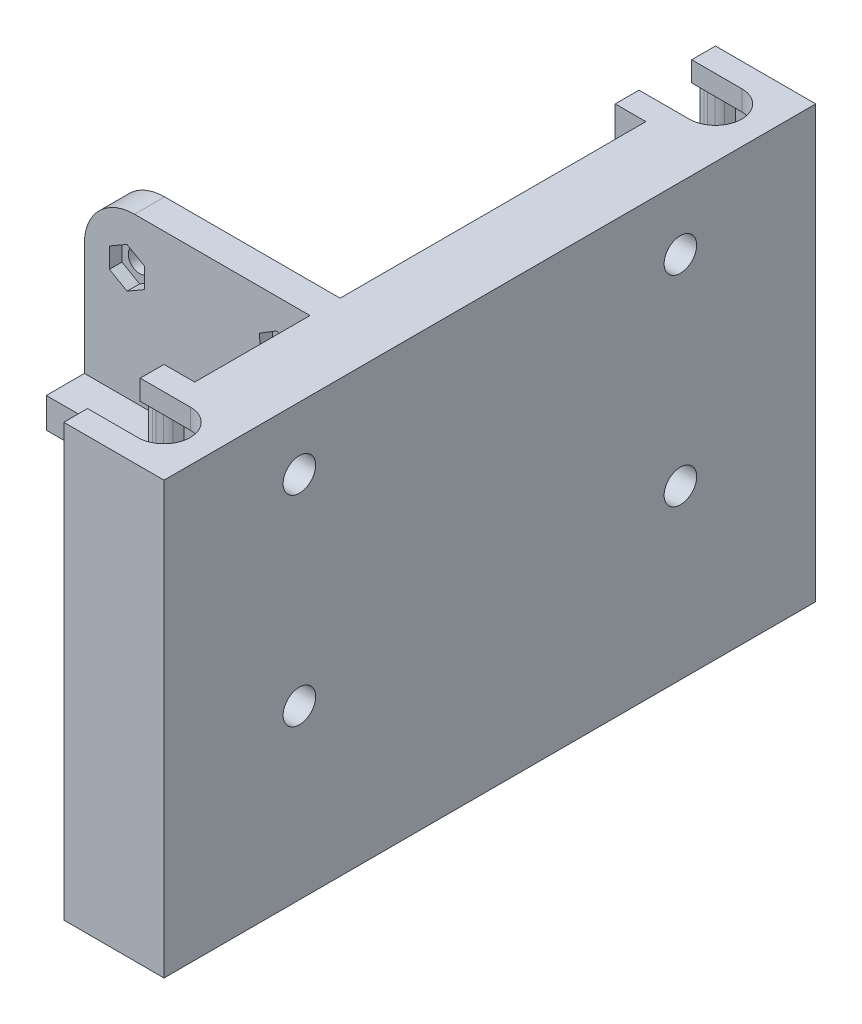
from build123d import *

# Parameters (mm, degrees)
BOSS_EXTRUDE1_DEPTH = 86
CUT_EXTRUDE1_REACH  = 88
CUT_EXTRUDE2_START  = -4
CUT_EXTRUDE2_DEPTH  = 17.2
CUT_EXTRUDE3_START  = -65
CUT_EXTRUDE3_DEPTH  = 17
SKETCH5_W           = 12
SKETCH5_H           = 71
BOSS_EXTRUDE2_DEPTH = 45
SKETCH6_W           = 6
SKETCH6_H           = 71
CUT_EXTRUDE4_DEPTH  = 45
CUT_EXTRUDE6_REACH  = 89
SKETCH8_R           = 2.25
SKETCH9_R           = 3.25
CUT_EXTRUDE7_DEPTH  = 59.8792938
CUT_EXTRUDE8_START  = -6
CUT_EXTRUDE8_DEPTH  = 2.5
FILLET1_R           = 10
SKETCH11_W          = 7.611163598
SKETCH11_H          = 6
BOSS_EXTRUDE3_DEPTH = 45


with BuildPart() as part:
    # Sketch1 → Boss-Extrude1 (new body)
    with BuildSketch(Plane(origin=(0, 0, 0), x_dir=(1, 0, 0), z_dir=(0, 1, 0))):
        Polygon((-7.52701042, -41.304091879), (-7.52701042, 88.695908121), (-27.52701042, 88.695908121), (-27.52701042, 68.695908121), (-21.40630422, 68.695908121), (-21.40630422, -21.304091879), (-27.52701042, -21.304091879), (-27.52701042, -41.304091879), align=None)
    extrude(amount=BOSS_EXTRUDE1_DEPTH)

    # Sketch2 → Cut-Extrude1 (cut, up to next)
    with BuildSketch(Plane(origin=(0, 86, 0), x_dir=(1, 0, 0), z_dir=(0, 1, 0)), mode=Mode.PRIVATE) as cut_extrude1_sk1:
        with BuildLine():
            Line((-17.52701042, 83.945908121), (-27.52701042, 83.945908121))
            Line((-27.52701042, 83.945908121), (-27.52701042, 73.445908121))
            Line((-27.52701042, 73.445908121), (-17.52701042, 73.445908121))
            ThreePointArc((-17.52701042, 73.445908121), (-12.27701042, 78.695908121), (-17.52701042, 83.945908121))
        make_face()
    cut_extrude1_tool1 = extrude(cut_extrude1_sk1.sketch, amount=-CUT_EXTRUDE1_REACH, mode=Mode.PRIVATE) & part.part
    add(cut_extrude1_tool1.solids().sort_by_distance((-20.41673, 86, -78.695908))[0], mode=Mode.SUBTRACT)
    # Sketch2 → Cut-Extrude1 (cut, up to next)
    with BuildSketch(Plane(origin=(0, 86, 0), x_dir=(1, 0, 0), z_dir=(0, 1, 0)), mode=Mode.PRIVATE) as cut_extrude1_sk2:
        with BuildLine():
            Line((-17.52701042, -26.054091879), (-27.52701042, -26.054091879))
            Line((-27.52701042, -26.054091879), (-27.52701042, -36.554091879))
            Line((-27.52701042, -36.554091879), (-17.52701042, -36.554091879))
            ThreePointArc((-17.52701042, -36.554091879), (-12.27701042, -31.304091879), (-17.52701042, -26.054091879))
        make_face()
    cut_extrude1_tool2 = extrude(cut_extrude1_sk2.sketch, amount=-CUT_EXTRUDE1_REACH, mode=Mode.PRIVATE) & part.part
    add(cut_extrude1_tool2.solids().sort_by_distance((-20.41673, 86, 31.304092))[0], mode=Mode.SUBTRACT)

    # Sketch4 → Cut-Extrude2 (cut)
    with BuildSketch(Plane.XZ.offset(CUT_EXTRUDE2_START)):
        with BuildLine():
            Line((-27.52701042, 24.384091879), (-27.52701042, 38.224091879))
            Line((-27.52701042, 38.224091879), (-25.949301656, 37.435237497))
            ThreePointArc((-25.949301656, 37.435237497), (-25.514380306, 37.2775939), (-25.054874465, 37.224091879))
            Line((-25.054874465, 37.224091879), (-23.550164803, 37.224091879))
            ThreePointArc((-23.550164803, 37.224091879), (-22.812872449, 37.364952297), (-22.179435405, 37.767691894))
            Line((-22.179435405, 37.767691894), (-21.05701042, 38.824091879))
            Line((-21.05701042, 38.824091879), (-17.52701042, 38.824091879))
            ThreePointArc((-17.52701042, 38.824091879), (-10.00701042, 31.304091879), (-17.52701042, 23.784091879))
            Line((-17.52701042, 23.784091879), (-21.05701042, 23.784091879))
            Line((-21.05701042, 23.784091879), (-22.179435405, 24.840491864))
            ThreePointArc((-22.179435405, 24.840491864), (-22.812872449, 25.243231461), (-23.550164803, 25.384091879))
            Line((-23.550164803, 25.384091879), (-25.054874465, 25.384091879))
            ThreePointArc((-25.054874465, 25.384091879), (-25.514380306, 25.330589858), (-25.949301656, 25.172946261))
            Line((-25.949301656, 25.172946261), (-27.52701042, 24.384091879))
        make_face()
        with BuildLine():
            Line((-21.05701042, -86.240594633), (-17.52701042, -86.240594633))
            ThreePointArc((-17.52701042, -86.240594633), (-9.994667164, -78.708251377), (-17.52701042, -71.175908121))
            Line((-17.52701042, -71.175908121), (-21.05701042, -71.175908121))
            Line((-21.05701042, -71.175908121), (-22.179435405, -72.232308106))
            ThreePointArc((-22.179435405, -72.232308106), (-22.812872449, -72.635047703), (-23.550164803, -72.775908121))
            Line((-23.550164803, -72.775908121), (-25.054874465, -72.775908121))
            ThreePointArc((-25.054874465, -72.775908121), (-25.514380306, -72.7224061), (-25.949301656, -72.564762503))
            Line((-25.949301656, -72.564762503), (-27.52701042, -71.775908121))
            Line((-27.52701042, -71.775908121), (-27.52701042, -85.615908121))
            Line((-27.52701042, -85.615908121), (-25.926859801, -84.840694199))
            ThreePointArc((-25.926859801, -84.840694199), (-25.502199364, -84.691261302), (-25.054874465, -84.640594633))
            Line((-25.054874465, -84.640594633), (-23.550164803, -84.640594633))
            ThreePointArc((-23.550164803, -84.640594633), (-22.812872449, -84.781455051), (-22.179435405, -85.184194648))
            Line((-22.179435405, -85.184194648), (-21.05701042, -86.240594633))
        make_face()
    extrude(amount=-CUT_EXTRUDE2_DEPTH, mode=Mode.SUBTRACT)

    # Sketch4_2 → Cut-Extrude3 (cut)
    with BuildSketch(Plane.XZ.offset(CUT_EXTRUDE3_START)):
        with BuildLine():
            Line((-27.52701042, 24.384091879), (-27.52701042, 38.224091879))
            Line((-27.52701042, 38.224091879), (-25.949301656, 37.435237497))
            ThreePointArc((-25.949301656, 37.435237497), (-25.514380306, 37.2775939), (-25.054874465, 37.224091879))
            Line((-25.054874465, 37.224091879), (-23.550164803, 37.224091879))
            ThreePointArc((-23.550164803, 37.224091879), (-22.812872449, 37.364952297), (-22.179435405, 37.767691894))
            Line((-22.179435405, 37.767691894), (-21.05701042, 38.824091879))
            Line((-21.05701042, 38.824091879), (-17.52701042, 38.824091879))
            ThreePointArc((-17.52701042, 38.824091879), (-10.00701042, 31.304091879), (-17.52701042, 23.784091879))
            Line((-17.52701042, 23.784091879), (-21.05701042, 23.784091879))
            Line((-21.05701042, 23.784091879), (-22.179435405, 24.840491864))
            ThreePointArc((-22.179435405, 24.840491864), (-22.812872449, 25.243231461), (-23.550164803, 25.384091879))
            Line((-23.550164803, 25.384091879), (-25.054874465, 25.384091879))
            ThreePointArc((-25.054874465, 25.384091879), (-25.514380306, 25.330589858), (-25.949301656, 25.172946261))
            Line((-25.949301656, 25.172946261), (-27.52701042, 24.384091879))
        make_face()
        with BuildLine():
            Line((-21.05701042, -86.240594633), (-17.52701042, -86.240594633))
            ThreePointArc((-17.52701042, -86.240594633), (-9.994667164, -78.708251377), (-17.52701042, -71.175908121))
            Line((-17.52701042, -71.175908121), (-21.05701042, -71.175908121))
            Line((-21.05701042, -71.175908121), (-22.179435405, -72.232308106))
            ThreePointArc((-22.179435405, -72.232308106), (-22.812872449, -72.635047703), (-23.550164803, -72.775908121))
            Line((-23.550164803, -72.775908121), (-25.054874465, -72.775908121))
            ThreePointArc((-25.054874465, -72.775908121), (-25.514380306, -72.7224061), (-25.949301656, -72.564762503))
            Line((-25.949301656, -72.564762503), (-27.52701042, -71.775908121))
            Line((-27.52701042, -71.775908121), (-27.52701042, -85.615908121))
            Line((-27.52701042, -85.615908121), (-25.926859801, -84.840694199))
            ThreePointArc((-25.926859801, -84.840694199), (-25.502199364, -84.691261302), (-25.054874465, -84.640594633))
            Line((-25.054874465, -84.640594633), (-23.550164803, -84.640594633))
            ThreePointArc((-23.550164803, -84.640594633), (-22.812872449, -84.781455051), (-22.179435405, -85.184194648))
            Line((-22.179435405, -85.184194648), (-21.05701042, -86.240594633))
        make_face()
    extrude(amount=-CUT_EXTRUDE3_DEPTH, mode=Mode.SUBTRACT)

    # Sketch5 → Boss-Extrude2 (add)
    with BuildSketch(Plane(origin=(-21.40630422, 0, 0), x_dir=(0, 0, -1), z_dir=(1, 0, 0))):
        with Locations((1.695908121, 50.5)):
            Rectangle(SKETCH5_W, SKETCH5_H)
    extrude(amount=-BOSS_EXTRUDE2_DEPTH)

    # Sketch6 → Cut-Extrude4 (cut)
    with BuildSketch(Plane.ZY.offset(66.40630422)):
        with Locations((1.304091879, 50.5)):
            Rectangle(SKETCH6_W, SKETCH6_H)
    extrude(amount=-CUT_EXTRUDE4_DEPTH, mode=Mode.SUBTRACT)

    # Sketch8 → Cut-Extrude6 (cut, up to next)
    with BuildSketch(Plane.XY.offset(-1.695908121), mode=Mode.PRIVATE) as cut_extrude6_sk1:
        with Locations((-57.90630422, 25)):
            Circle(SKETCH8_R)
    cut_extrude6_tool1 = extrude(cut_extrude6_sk1.sketch, amount=-CUT_EXTRUDE6_REACH, mode=Mode.PRIVATE) & part.part
    add(cut_extrude6_tool1.solids().sort_by_distance((-57.906304, 25, -1.695908))[0], mode=Mode.SUBTRACT)
    # Sketch8 → Cut-Extrude6 (cut, up to next)
    with BuildSketch(Plane.XY.offset(-1.695908121), mode=Mode.PRIVATE) as cut_extrude6_sk2:
        with Locations((-57.90630422, 76)):
            Circle(SKETCH8_R)
    cut_extrude6_tool2 = extrude(cut_extrude6_sk2.sketch, amount=-CUT_EXTRUDE6_REACH, mode=Mode.PRIVATE) & part.part
    add(cut_extrude6_tool2.solids().sort_by_distance((-57.906304, 76, -1.695908))[0], mode=Mode.SUBTRACT)
    # Sketch8 → Cut-Extrude6 (cut, up to next)
    with BuildSketch(Plane.XY.offset(-1.695908121), mode=Mode.PRIVATE) as cut_extrude6_sk3:
        with Locations((-27.90630422, 25)):
            Circle(SKETCH8_R)
    cut_extrude6_tool3 = extrude(cut_extrude6_sk3.sketch, amount=-CUT_EXTRUDE6_REACH, mode=Mode.PRIVATE) & part.part
    add(cut_extrude6_tool3.solids().sort_by_distance((-27.906304, 25, -1.695908))[0], mode=Mode.SUBTRACT)
    # Sketch8 → Cut-Extrude6 (cut, up to next)
    with BuildSketch(Plane.XY.offset(-1.695908121), mode=Mode.PRIVATE) as cut_extrude6_sk4:
        with Locations((-27.90630422, 76)):
            Circle(SKETCH8_R)
    cut_extrude6_tool4 = extrude(cut_extrude6_sk4.sketch, amount=-CUT_EXTRUDE6_REACH, mode=Mode.PRIVATE) & part.part
    add(cut_extrude6_tool4.solids().sort_by_distance((-27.906304, 76, -1.695908))[0], mode=Mode.SUBTRACT)

    # Sketch9 → Cut-Extrude7 (cut, through all)
    with BuildSketch(Plane(origin=(-7.52701042, 0, 0), x_dir=(0, 0, -1), z_dir=(1, 0, 0))):
        with Locations((61.695908121, 33.5)):
            Circle(SKETCH9_R)
        with Locations((-14.304091879, 33.5)):
            Circle(SKETCH9_R)
        with Locations((-14.304091879, 73.5)):
            Circle(SKETCH9_R)
        with Locations((61.695908121, 73.5)):
            Circle(SKETCH9_R)
    extrude(amount=-CUT_EXTRUDE7_DEPTH, mode=Mode.SUBTRACT)

    # Sketch10 → Cut-Extrude8 (cut)
    with BuildSketch(Plane(origin=(0, 0, -7.695908121), x_dir=(-1, 0, 0), z_dir=(0, 0, -1)).offset(CUT_EXTRUDE8_START)):
        Polygon((61.40630422, 27.020725942), (57.90630422, 29.041451884), (54.40630422, 27.020725942), (54.40630422, 22.979274058), (57.90630422, 20.958548116), (61.40630422, 22.979274058), align=None)
        Polygon((61.40630422, 78.020725942), (57.90630422, 80.041451884), (54.40630422, 78.020725942), (54.40630422, 73.979274058), (57.90630422, 71.958548116), (61.40630422, 73.979274058), align=None)
        Polygon((24.40630422, 22.979274058), (27.90630422, 20.958548116), (31.40630422, 22.979274058), (31.40630422, 27.020725942), (27.90630422, 29.041451884), (24.40630422, 27.020725942), align=None)
        Polygon((27.795986428, 71.960054045), (31.349841151, 73.884489013), (31.460158942, 77.924434968), (28.016622011, 80.039945955), (24.462767289, 78.115510987), (24.352449497, 74.075565032), align=None)
    extrude(amount=CUT_EXTRUDE8_DEPTH, mode=Mode.SUBTRACT)

    # Fillet1
    fillet1_edges = [part.edges().sort_by_distance(p)[0] for p in [
        (-66.40630422, 86, -4.695908121),
        (-66.40630422, 15, -4.695908121),
    ]]
    fillet(fillet1_edges, radius=FILLET1_R)

    # Sketch11 → Boss-Extrude3 (add)
    with BuildSketch(Plane.ZY.offset(21.40630422)):
        with Locations((2.109673678, 50.5)):
            Rectangle(SKETCH11_W, SKETCH11_H)
    extrude(amount=BOSS_EXTRUDE3_DEPTH)


solid = part.part
